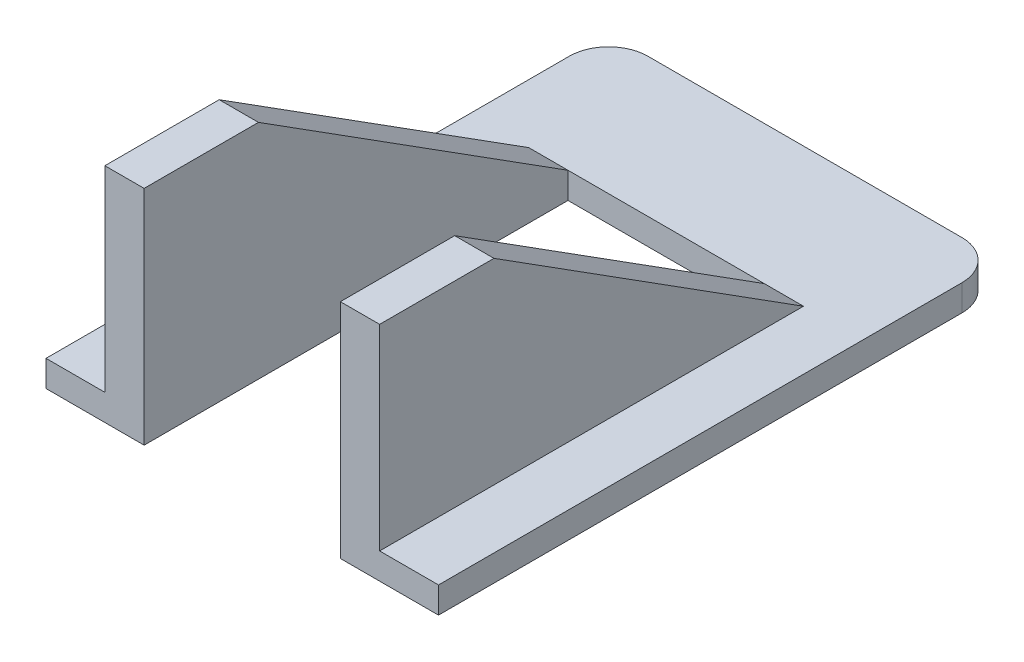
from build123d import *

# Parameters (mm, degrees)
CROQUIS2_W              = 43
CROQUIS2_H              = 30
SALIENTE_EXTRUIR1_DEPTH = 30
CROQUIS3_W              = 42.529407755
CROQUIS3_H              = 25.558495791
CORTAR_EXTRUIR1_DEPTH   = 30
CORTAR_EXTRUIR2_START   = -7.5
CORTAR_EXTRUIR2_DEPTH   = 15
CORTAR_EXTRUIR4_DEPTH   = 4.5
CORTAR_EXTRUIR5_DEPTH   = 4.5
REDONDEO1_R             = 3
CROQUIS8_W              = 15
CROQUIS8_H              = 32.397186909
CORTAR_EXTRUIR6_DEPTH   = 4.5
CROQUIS9_W              = 120.283196461
CROQUIS9_H              = 78.810135234
CORTAR_EXTRUIR7_DEPTH   = 22.5
CORTAR_EXTRUIR8_DEPTH   = 22.5


with BuildPart() as part:
    # Croquis2 → Saliente-Extruir1 (new body)
    with BuildSketch(Plane(origin=(0, 0, 0), x_dir=(0, 0, -1), z_dir=(1, 0, 0))):
        with Locations((-19.783269962, -13.522813688)):
            Rectangle(CROQUIS2_W, CROQUIS2_H)
    extrude(amount=SALIENTE_EXTRUIR1_DEPTH)

    # Croquis3 → Cortar-Extruir1 (cut)
    with BuildSketch(Plane(origin=(30, 0, 0), x_dir=(0, 0, -1), z_dir=(1, 0, 0))):
        with Locations((-17.018566085, -31.302061584)):
            Rectangle(CROQUIS3_W, CROQUIS3_H)
        Polygon((-31.675073764, 1.477186312), (-3.283269962, -16.522813688), (1.716730038, -16.522813688), (1.716730038, 1.477186312), align=None)
    extrude(amount=-CORTAR_EXTRUIR1_DEPTH, mode=Mode.SUBTRACT)

    # Croquis4 → Cortar-Extruir2 (cut)
    with BuildSketch(Plane(origin=(30, 0, 0), x_dir=(0, 0, -1), z_dir=(1, 0, 0)).offset(CORTAR_EXTRUIR2_START)):
        Polygon((-41.283269962, -1.522813688), (-32.545919554, -1.522813688), (-8.886083053, -16.522813688), (-41.283269962, -16.522813688), align=None)
    extrude(amount=-CORTAR_EXTRUIR2_DEPTH, mode=Mode.SUBTRACT)

    # Croquis5 → Cortar-Extruir4 (cut)
    with BuildSketch(Plane(origin=(30, 0, 0), x_dir=(0, 0, -1), z_dir=(1, 0, 0))):
        Polygon((-3.283269962, -16.522813688), (-41.283269962, -16.522813688), (-41.283269962, 1.477186312), (-31.675073764, 1.477186312), align=None)
    extrude(amount=-CORTAR_EXTRUIR4_DEPTH, mode=Mode.SUBTRACT)

    # Croquis6 → Cortar-Extruir5 (cut)
    with BuildSketch(Plane.ZY):
        Polygon((3.283269962, -16.522813688), (41.283269962, -16.522813688), (41.283269962, 1.477186312), (31.675073764, 1.477186312), align=None)
    extrude(amount=-CORTAR_EXTRUIR5_DEPTH, mode=Mode.SUBTRACT)

    # Redondeo1
    redondeo1_edges = [part.edges().sort_by_distance(p)[0] for p in [
        (0, -17.522813688, -1.716730038),
        (30, -17.522813688, -1.716730038),
    ]]
    fillet(redondeo1_edges, radius=REDONDEO1_R)

    # Croquis8 → Cortar-Extruir6 (cut)
    with BuildSketch(Plane(origin=(0, -16.522813688, 0), x_dir=(1, 0, 0), z_dir=(0, 1, 0))):
        with Locations((15, -25.084676508)):
            Rectangle(CROQUIS8_W, CROQUIS8_H)
    extrude(amount=-CORTAR_EXTRUIR6_DEPTH, mode=Mode.SUBTRACT)

    # Croquis9 → Cortar-Extruir7 (cut)
    with BuildSketch(Plane.XZ.offset(18.522813688)):
        with Locations((17.6156444, 62.089659259)):
            Rectangle(CROQUIS9_W, CROQUIS9_H)
    extrude(amount=CORTAR_EXTRUIR7_DEPTH, mode=Mode.SUBTRACT)

    # Croquis10 → Cortar-Extruir8 (cut)
    with BuildSketch(Plane(origin=(25.5, 0, 0), x_dir=(0, 0, -1), z_dir=(1, 0, 0))):
        Polygon((-41.283269962, -1.522813688), (-32.545919554, -1.522813688), (-8.886083053, -16.522813688), (1.716730038, -16.522813688), (-27.710183608, 4.902177411), (-44.228495628, 5.2702735), align=None)
    extrude(amount=-CORTAR_EXTRUIR8_DEPTH, mode=Mode.SUBTRACT)


solid = part.part
